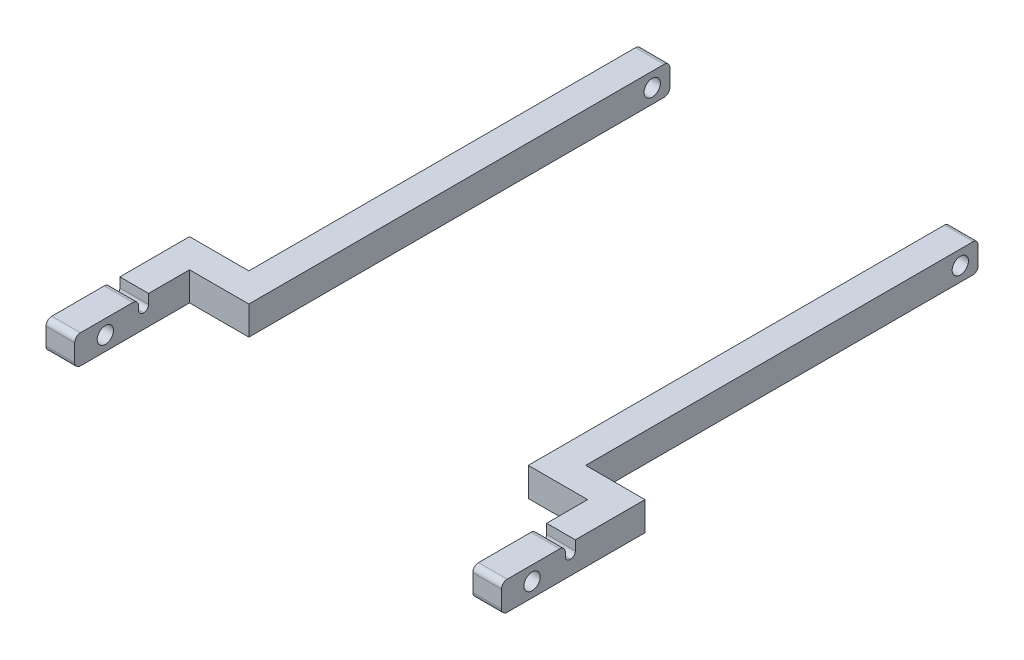
from build123d import *

# Parameters (mm, degrees)
OUTER_LEGS_DEPTH            = 15
OUTER_LEGS_2_DEPTH          = 15
SKETCH7_R                   = 4.25
LOWER_DOWEL_HOLE_DEPTH      = 224
LOWER_DOWEL_HOLE_DEPTH_BACK = 16
SKETCH8_W                   = 5.2
SKETCH8_H                   = 7.5
CUT_EXTRUDE4_DEPTH          = 32
CUT_EXTRUDE4_DEPTH_BACK     = 208
SKETCH6_R                   = 4.25
HINGE_HOLE_DEPTH            = 32
HINGE_HOLE_DEPTH_BACK       = 208
FILLET3_R                   = 2.5
FILLET5_R                   = 3
FILLET6_R                   = 3
FILLET10_R                  = 3
FILLET11_R                  = 3
FILLET12_R                  = 2.5
FILLET13_R                  = 2.5
FILLET14_R                  = 3


with BuildPart() as part:
    # Sketch2 → outer legs (new body)
    with BuildSketch(Plane(origin=(0, 0, 0), x_dir=(1, 0, 0), z_dir=(0, 1, 0))):
        Polygon((0, 75), (0, 280), (15, 280), (15, 60), (-16, 60), (-16, 0), (-31, 0), (-31, 75), align=None)
    extrude(amount=OUTER_LEGS_DEPTH)


with BuildPart() as body_2:
    # Sketch2 → outer legs 2 (new body)
    with BuildSketch(Plane(origin=(0, 0, 0), x_dir=(1, 0, 0), z_dir=(0, 1, 0))):
        Polygon((176, 75), (176, 280), (161, 280), (161, 60), (192, 60), (192, 0), (207, 0), (207, 75), align=None)
    extrude(amount=OUTER_LEGS_2_DEPTH)


with BuildPart() as lower_dowel_hole_tool:
    # Sketch7 → LOWER DOWEL HOLE (new body, two sides)
    with BuildSketch(Plane.ZY.offset(-192)) as lower_dowel_hole_sk:
        with Locations((-16, 7.5)):
            Circle(SKETCH7_R)
    extrude(amount=LOWER_DOWEL_HOLE_DEPTH)
    extrude(lower_dowel_hole_sk.sketch, amount=-LOWER_DOWEL_HOLE_DEPTH_BACK)


with BuildPart() as part_1:
    add(part.part)

    # LOWER DOWEL HOLE: cut by lower_dowel_hole_tool
    add(lower_dowel_hole_tool.part, mode=Mode.SUBTRACT)


with BuildPart() as body_2_1:
    add(body_2.part)

    # LOWER DOWEL HOLE: cut by lower_dowel_hole_tool
    add(lower_dowel_hole_tool.part, mode=Mode.SUBTRACT)


with BuildPart() as cut_extrude4_tool:
    # Sketch8 → Cut-Extrude4 (new body, two sides)
    with BuildSketch(Plane.ZY) as cut_extrude4_sk:
        with Locations((-36, 11.25)):
            Rectangle(SKETCH8_W, SKETCH8_H)
    extrude(amount=CUT_EXTRUDE4_DEPTH)
    extrude(cut_extrude4_sk.sketch, amount=-CUT_EXTRUDE4_DEPTH_BACK)


with BuildPart() as part_2:
    add(part_1.part)

    # Cut-Extrude4: cut by cut_extrude4_tool
    add(cut_extrude4_tool.part, mode=Mode.SUBTRACT)


with BuildPart() as body_2_2:
    add(body_2_1.part)

    # Cut-Extrude4: cut by cut_extrude4_tool
    add(cut_extrude4_tool.part, mode=Mode.SUBTRACT)


with BuildPart() as hinge_hole_tool:
    # Sketch6 → HINGE HOLE (new body, two sides)
    with BuildSketch(Plane.ZY) as hinge_hole_sk:
        with Locations((-270.75, 7.5)):
            Circle(SKETCH6_R)
    extrude(amount=HINGE_HOLE_DEPTH)
    extrude(hinge_hole_sk.sketch, amount=-HINGE_HOLE_DEPTH_BACK)


with BuildPart() as part_3:
    add(part_2.part)

    # HINGE HOLE: cut by hinge_hole_tool
    add(hinge_hole_tool.part, mode=Mode.SUBTRACT)

    # Fillet5
    fillet5_edges = [part_3.edges().sort_by_distance(p)[0] for p in [
        (-23.5, 15, -33.4),
    ]]
    fillet(fillet5_edges, radius=FILLET5_R)

    # Fillet10
    fillet10_edges = [part_3.edges().sort_by_distance(p)[0] for p in [
        (-23.5, 15, 0),
        (-23.5, 0, 0),
    ]]
    fillet(fillet10_edges, radius=FILLET10_R)

    # Fillet12
    fillet12_edges = [part_3.edges().sort_by_distance(p)[0] for p in [
        (-23.5, 7.5, -38.6),
        (-23.5, 7.5, -33.4),
    ]]
    fillet(fillet12_edges, radius=FILLET12_R)

    # Fillet14
    fillet14_edges = [part_3.edges().sort_by_distance(p)[0] for p in [
        (7.5, 0, -280),
        (7.5, 15, -280),
    ]]
    fillet(fillet14_edges, radius=FILLET14_R)


with BuildPart() as body_2_3:
    add(body_2_2.part)

    # HINGE HOLE: cut by hinge_hole_tool
    add(hinge_hole_tool.part, mode=Mode.SUBTRACT)

    # Fillet3
    fillet3_edges = [body_2_3.edges().sort_by_distance(p)[0] for p in [
        (168.5, 0, -280),
        (168.5, 15, -280),
    ]]
    fillet(fillet3_edges, radius=FILLET3_R)

    # Fillet6
    fillet6_edges = [body_2_3.edges().sort_by_distance(p)[0] for p in [
        (199.5, 15, -33.4),
    ]]
    fillet(fillet6_edges, radius=FILLET6_R)

    # Fillet11
    fillet11_edges = [body_2_3.edges().sort_by_distance(p)[0] for p in [
        (199.5, 0, 0),
        (199.5, 15, 0),
    ]]
    fillet(fillet11_edges, radius=FILLET11_R)

    # Fillet13
    fillet13_edges = [body_2_3.edges().sort_by_distance(p)[0] for p in [
        (199.5, 7.5, -33.4),
        (199.5, 7.5, -38.6),
    ]]
    fillet(fillet13_edges, radius=FILLET13_R)


solid = Compound([part_3.part, body_2_3.part])
